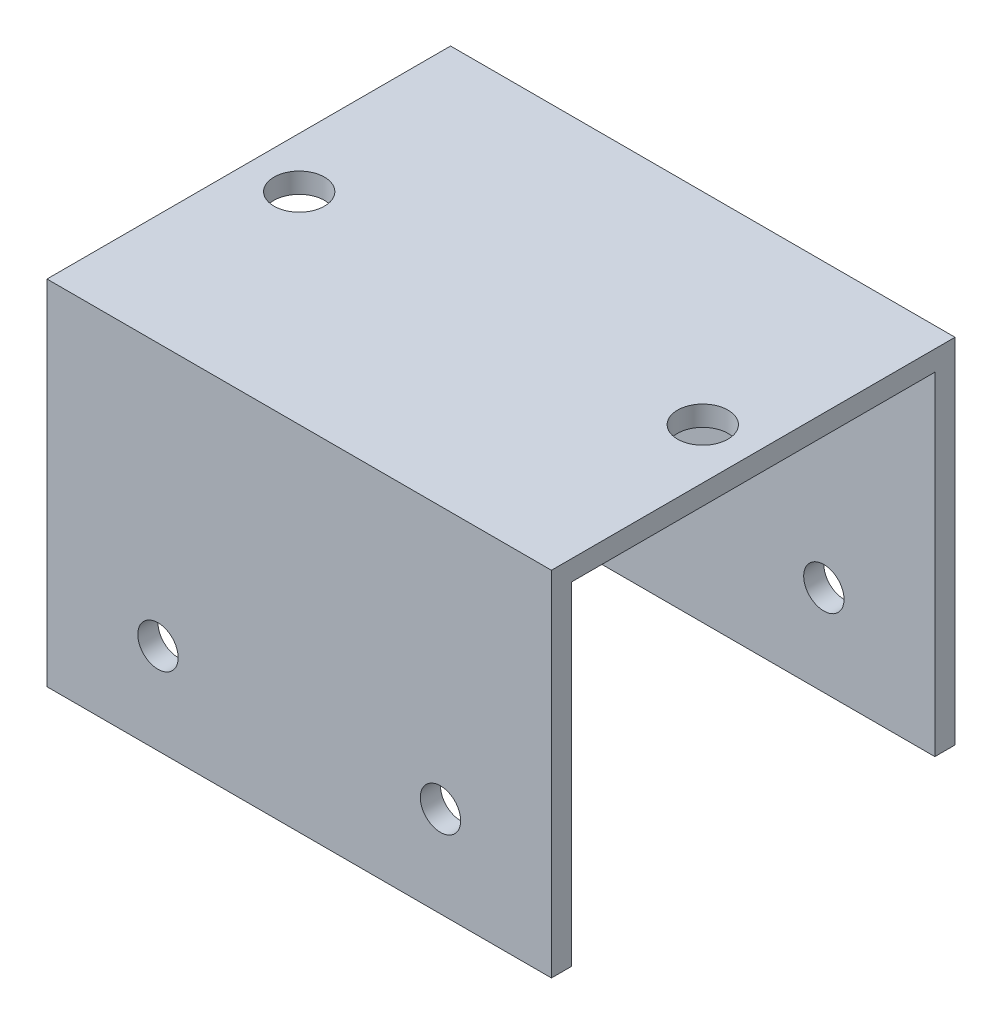
from build123d import *

# Parameters (mm, degrees)
EXTRUDE_1_DEPTH     = 25
SKETCH_2_R          = 2
CUT_EXTRUDE_1_DEPTH = 41
SKETCH_3_R          = 2.5
CUT_EXTRUDE_2_DEPTH = 10


with BuildPart() as part:
    # 草图1 → 凸台-拉伸1 (new body, symmetric)
    with BuildSketch(Plane(origin=(0, 0, 0), x_dir=(0, 0, -1), z_dir=(1, 0, 0))):
        Polygon((18, 33), (18, 0), (20, 0), (20, 35), (-20, 35), (-20, 0), (-18, 0), (-18, 33), align=None)
    extrude(amount=EXTRUDE_1_DEPTH, both=True)

    # 草图2 → 切除-拉伸1 (cut, through all)
    with BuildSketch(Plane.XY.offset(20)):
        with Locations((-14, 9)):
            Circle(SKETCH_2_R)
        with Locations((14, 9)):
            Circle(SKETCH_2_R)
    extrude(amount=-CUT_EXTRUDE_1_DEPTH, mode=Mode.SUBTRACT)

    # 草图3 → 切除-拉伸2 (cut)
    with BuildSketch(Plane(origin=(0, 35, 0), x_dir=(1, 0, 0), z_dir=(0, 1, 0))):
        with Locations((-20, 0)):
            Circle(SKETCH_3_R)
        with Locations((20, 0)):
            Circle(SKETCH_3_R)
    extrude(amount=-CUT_EXTRUDE_2_DEPTH, mode=Mode.SUBTRACT)


solid = part.part
